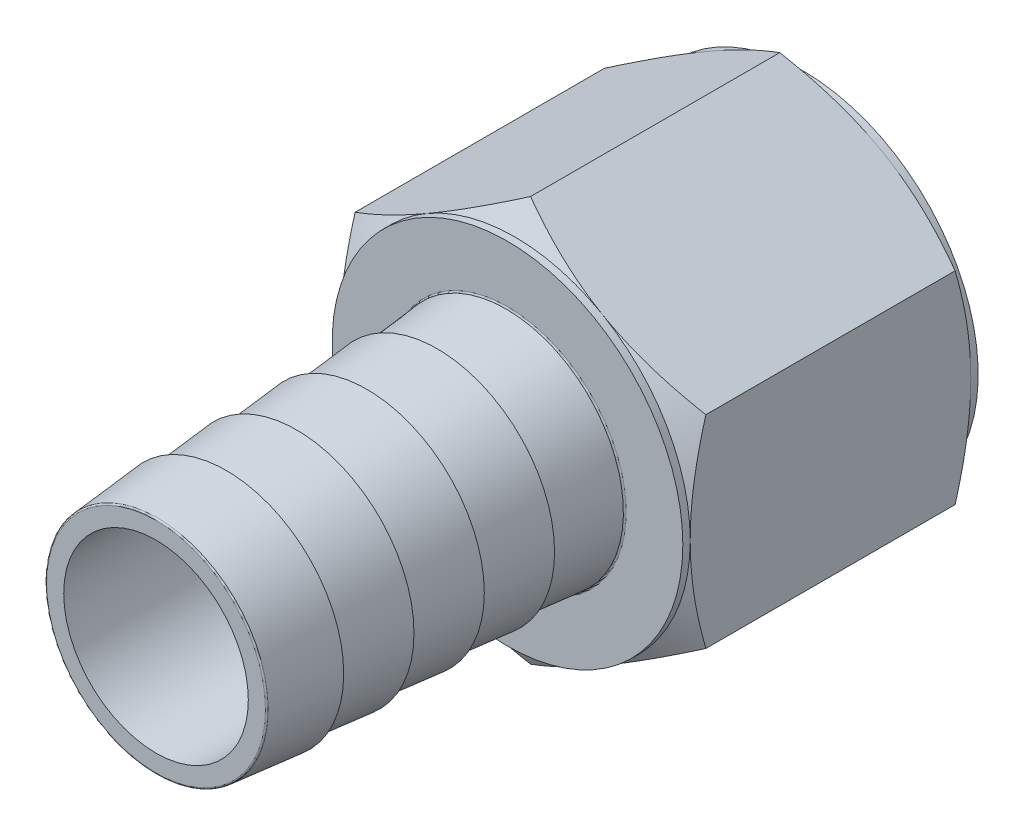
from build123d import *

# Parameters (mm, degrees)
LPATTERN1_COUNT              = 4
LPATTERN1_PITCH              = 6.0452
BOSS_EXTRUDE1_DEPTH          = 25.4
CUT_EXTRUDE1_START           = -0.635
SKETCH5_OUTSIDE_W            = 179.522
SKETCH5_OUTSIDE_H            = 184.188
SKETCH5_OUTSIDE_R            = 15.08125
CUT_EXTRUDE1_DEPTH           = 38.369131087
CUT_EXTRUDE1_TAPER           = 60
CUT_EXTRUDE1_OTHER_WAY_DEPTH = 0.635
CUT_EXTRUDE2_START           = -0.635
SKETCH6_OUTSIDE_W            = 256.438
SKETCH6_OUTSIDE_H            = 261.104
SKETCH6_OUTSIDE_R            = 15.08125
CUT_EXTRUDE2_DEPTH           = 60.572597358
CUT_EXTRUDE2_TAPER           = 60
CUT_EXTRUDE2_OTHER_WAY_DEPTH = 0.635
SKETCH7_W                    = 55.626
SKETCH7_H                    = 7.9375
FILLET1_R                    = 0.127


with BuildPart() as part:
    # Sketch2 → Revolve1 (revolve)
    with BuildSketch(Plane(origin=(0, 0, 0), x_dir=(0, 0, -1), z_dir=(1, 0, 0)), mode=Mode.PRIVATE) as revolve1_sk:
        Polygon((-30.226, 9.525), (-6.0452, 9.525), (0, 10.0965), (0, 0), (-30.226, 0), align=None)
    revolve(revolve1_sk.sketch.rotate(Axis((0, 0, 30.226), (0, 0, -1)), 180), axis=Axis((0, 0, 30.226), (0, 0, -1)))

    # Sketch3 → Revolve2 (revolve)
    with BuildSketch(Plane(origin=(0, 0, 0), x_dir=(0, 0, -1), z_dir=(1, 0, 0)), mode=Mode.PRIVATE) as revolve2_sk:
        Polygon((-30.226, 9.525), (-24.1808, 10.0965), (-24.1808, 9.525), align=None)
    revolve2 = revolve(revolve2_sk.sketch.rotate(Axis((0, 0, 0), (0, 0, 1)), 180), axis=Axis((0, 0, 0), (0, 0, 1)))

    # LPattern1: Revolve2 ×4
    with Locations(*[(0, 0, -i * LPATTERN1_PITCH) for i in range(1, LPATTERN1_COUNT)]):
        add(revolve2)

    # Sketch4 → Boss-Extrude1 (add)
    with BuildSketch(Plane(origin=(0, 0, 0), x_dir=(-1, 0, 0), z_dir=(0, 0, -1))):
        Polygon((0, 17.414327494), (-15.08125, 8.707163747), (-15.08125, -8.707163747), (0, -17.414327494), (15.08125, -8.707163747), (15.08125, 8.707163747), align=None)
    extrude(amount=BOSS_EXTRUDE1_DEPTH)

    # Sketch5 outside → Cut-Extrude1 (cut)
    with BuildSketch(Plane.XY.offset(CUT_EXTRUDE1_START)):
        Rectangle(SKETCH5_OUTSIDE_W, SKETCH5_OUTSIDE_H)
        Circle(SKETCH5_OUTSIDE_R, mode=Mode.SUBTRACT)
    extrude(amount=-CUT_EXTRUDE1_DEPTH, taper=CUT_EXTRUDE1_TAPER, mode=Mode.SUBTRACT)

    # Sketch5 outside → Cut-Extrude1 other way (cut)
    with BuildSketch(Plane.XY.offset(CUT_EXTRUDE1_START)):
        Rectangle(SKETCH5_OUTSIDE_W, SKETCH5_OUTSIDE_H)
        Circle(SKETCH5_OUTSIDE_R, mode=Mode.SUBTRACT)
    extrude(amount=CUT_EXTRUDE1_OTHER_WAY_DEPTH, mode=Mode.SUBTRACT)

    # Sketch6 outside → Cut-Extrude2 (cut)
    with BuildSketch(Plane(origin=(0, 0, -25.4), x_dir=(-1, 0, 0), z_dir=(0, 0, -1)).offset(CUT_EXTRUDE2_START)):
        Rectangle(SKETCH6_OUTSIDE_W, SKETCH6_OUTSIDE_H)
        with Locations(Location((0, 0, 0), (0, 0, 180))):
            Circle(SKETCH6_OUTSIDE_R, mode=Mode.SUBTRACT)
    extrude(amount=-CUT_EXTRUDE2_DEPTH, taper=CUT_EXTRUDE2_TAPER, mode=Mode.SUBTRACT)

    # Sketch6 outside → Cut-Extrude2 other way (cut)
    with BuildSketch(Plane(origin=(0, 0, -25.4), x_dir=(-1, 0, 0), z_dir=(0, 0, -1)).offset(CUT_EXTRUDE2_START)):
        Rectangle(SKETCH6_OUTSIDE_W, SKETCH6_OUTSIDE_H)
        with Locations(Location((0, 0, 0), (0, 0, 180))):
            Circle(SKETCH6_OUTSIDE_R, mode=Mode.SUBTRACT)
    extrude(amount=CUT_EXTRUDE2_OTHER_WAY_DEPTH, mode=Mode.SUBTRACT)

    # Sketch7 → Cut-Revolve1 (revolve, cut)
    with BuildSketch(Plane(origin=(0, 0, 0), x_dir=(0, 0, -1), z_dir=(1, 0, 0)), mode=Mode.PRIVATE) as cut_revolve1_sk:
        with Locations((-2.413, 3.96875)):
            Rectangle(SKETCH7_W, SKETCH7_H)
    revolve(cut_revolve1_sk.sketch.rotate(Axis((0, 0, 30.226), (0, 0, -1)), 270), axis=Axis((0, 0, 30.226), (0, 0, -1)), mode=Mode.SUBTRACT)

    # Sketch8 → Cut-Revolve2 (revolve, cut)
    with BuildSketch(Plane(origin=(0, 0, 0), x_dir=(0, 0, -1), z_dir=(1, 0, 0)), mode=Mode.PRIVATE) as cut_revolve2_sk:
        Polygon((25.4, 13.335), (11.53922, 12.903443324), (11.53922, 11.7078125), (4.504456534, 0), (25.4, 0), align=None)
    revolve(cut_revolve2_sk.sketch.rotate(Axis((0, 0, 30.226), (0, 0, -1)), 270), axis=Axis((0, 0, 30.226), (0, 0, -1)), mode=Mode.SUBTRACT)

    # Fillet1
    fillet1_edges = [part.edges().sort_by_distance(p)[0] for p in [
        (0, 9.525, 30.226),
        (0, 10.0965, 0),
    ]]
    fillet(fillet1_edges, radius=FILLET1_R)


solid = part.part
